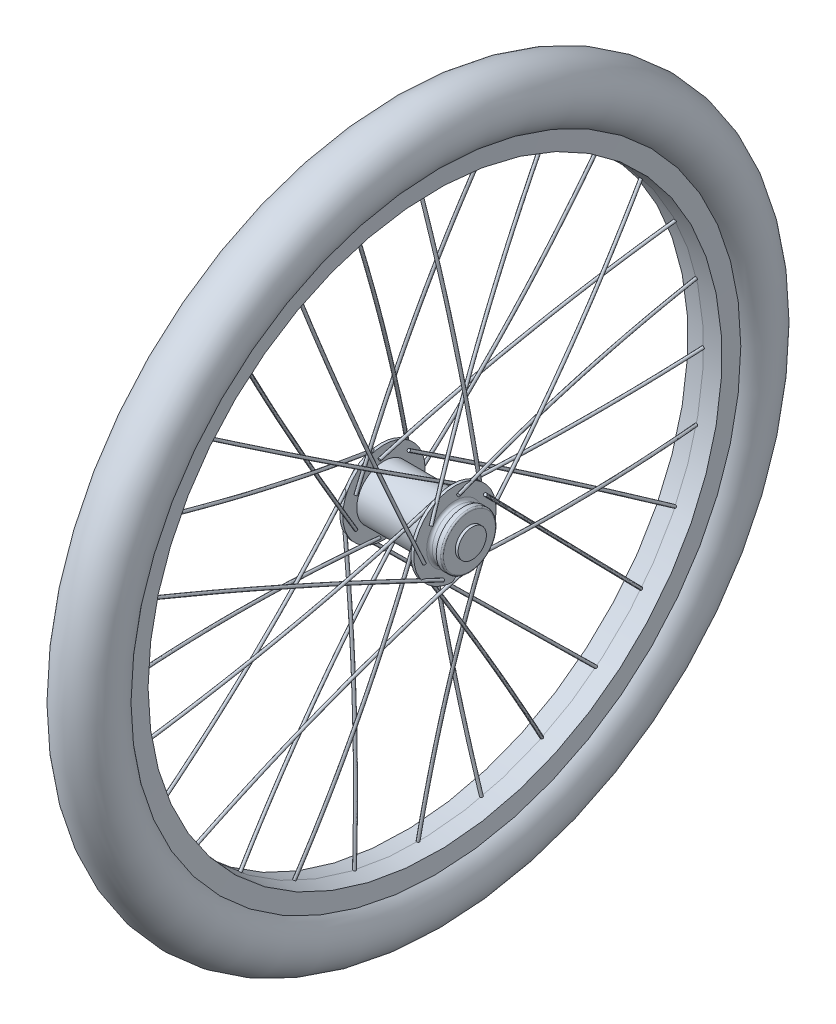
from build123d import *

# Parameters (mm, degrees)
SWEEP1_PROFILE_R      = 1
SWEEP2_PROFILE_R      = 1
BODY_MOVE_COPY1_ANGLE = 12.857142857
CIRPATTERN2_COUNT     = 7
SKETCH38_R            = 18
BOSS_EXTRUDE1_DEPTH   = 6.1
FILLET1_R             = 2
SKETCH39_R            = 19.35
BOSS_EXTRUDE2_DEPTH   = 4.1
FILLET2_R             = 1
SKETCH40_R            = 10
BOSS_EXTRUDE3_DEPTH   = 2


with BuildPart() as part:
    # Sketch1 → Revolve1 (revolve)
    with BuildSketch(Plane.XY):
        with BuildLine():
            Line((12, 202.6), (12.5, 215.46))
            ThreePointArc((12.5, 215.46), (0, 253.334537031), (-12.5, 215.46))
            Line((-12.5, 215.46), (-12, 202.6))
            Line((-12, 202.6), (0, 201.6))
            Line((0, 201.6), (12, 202.6))
        make_face()
    revolve(axis=Axis((0, 0, 0), (1, 0, 0)))


with BuildPart() as body_2:
    # Sketch4 → Revolve2 (revolve)
    with BuildSketch(Plane.XY):
        Polygon((26.125, 0), (26.125, 29.075), (24.075, 29.075), (24.075, 19.14), (0, 19.14), (0, 0), align=None)
    revolve(axis=Axis((0, 0, 0), (1, 0, 0)))

    # Mirror2: body 2 across plane


with BuildPart() as body_2_1:
    add(body_2.part)
    add(body_2.part.mirror(Plane(origin=(0, 0, 0), x_dir=(0, 0, 1), z_dir=(1, 0, 0))))

    # Sketch38 → Boss-Extrude1 (add)
    with BuildSketch(Plane(origin=(26.125, 0, 0), x_dir=(0, 0, -1), z_dir=(1, 0, 0))):
        Circle(SKETCH38_R)
    extrude(amount=BOSS_EXTRUDE1_DEPTH)

    # Fillet1
    fillet1_edges = [body_2_1.edges().sort_by_distance(p)[0] for p in [
        (26.125, 0, 18),
    ]]
    fillet(fillet1_edges, radius=FILLET1_R)

    # Sketch39 → Boss-Extrude2 (add)
    with BuildSketch(Plane(origin=(32.225, 0, 0), x_dir=(0, 0, -1), z_dir=(1, 0, 0))):
        Circle(SKETCH39_R)
    extrude(amount=BOSS_EXTRUDE2_DEPTH)

    # Fillet2
    fillet2_edges = [body_2_1.edges().sort_by_distance(p)[0] for p in [
        (36.325, 0, 19.35),
    ]]
    fillet(fillet2_edges, radius=FILLET2_R)

    # Sketch40 → Boss-Extrude3 (add)
    with BuildSketch(Plane(origin=(36.325, 0, 0), x_dir=(0, 0, -1), z_dir=(1, 0, 0))):
        Circle(SKETCH40_R)
    extrude(amount=BOSS_EXTRUDE3_DEPTH)


with BuildPart() as body_3:
    # Sweep1: sweep along a curve in space
    with BuildLine() as sweep1_path:
        add(Edge.make_bspline(
            [(21.775, 5.451762882, -23.885733848), (18.130892143, 104.226820854, -11.857510805), (0, 201.6, 0)],
            knots=[0, 0, 0, 1, 1, 1], degree=2))
    # Sweep1 profile (on start of the path) → Sweep1 (sweep)
    with BuildSketch(Plane(origin=(21.775, 5.451762882, -23.885733848), x_dir=(0, -0.12088092385501184, 0.9926670147879192), z_dir=(-0.03659792616302885, 0.9920019988619001, 0.12079994227879551))):
        Circle(SWEEP1_PROFILE_R)
    sweep(path=sweep1_path.line)


with BuildPart() as body_4:
    # Sweep2: sweep along a curve in space
    with BuildLine() as sweep2_path:
        add(Edge.make_bspline(
            [(28.425, 15.275500146, 19.15487132), (7.096832985, 97.519487238, -33.558178335), (0, 181.635323769, -87.470961806)],
            knots=[0, 0, 0, 1, 1, 1], degree=2))
    # Sweep2 profile (on start of the path) → Sweep2 (sweep)
    with BuildSketch(Plane(origin=(28.425, 15.275500146, 19.15487132), x_dir=(0, 0.5396120251914962, 0.8419138092873476), z_dir=(-0.2133069514539331, 0.8225373586849968, -0.5271929798744844))):
        Circle(SWEEP2_PROFILE_R)
    sweep(path=sweep2_path.line)


with BuildPart() as body_5:
    # Mirror3: mirrored copy
    add(body_3.part.mirror(Plane(origin=(0, 0, 0), x_dir=(0, 0, 1), z_dir=(1, 0, 0))))


with BuildPart() as body_6:
    # Mirror3 2: mirrored copy
    add(body_4.part.mirror(Plane(origin=(0, 0, 0), x_dir=(0, 0, 1), z_dir=(1, 0, 0))))


with BuildPart() as body_5_1:
    # Body-Move_Copy1: moved
    add(body_5.part.rotate(Axis((0, 0, 0), (1, 0, 0)), BODY_MOVE_COPY1_ANGLE))


with BuildPart() as body_6_1:
    # Body-Move_Copy1: moved
    add(body_6.part.rotate(Axis((0, 0, 0), (1, 0, 0)), BODY_MOVE_COPY1_ANGLE))


with BuildPart() as body_7:
    # Mirror4: mirrored copy
    add(body_6_1.part.mirror(Plane.XY))


with BuildPart() as body_8:
    # Mirror4 2: mirrored copy
    add(body_5_1.part.mirror(Plane.XY))


with BuildPart() as cirpattern2_1:
    # CirPattern2: pattern copy
    add(body_4.part.rotate(Axis((-80.9, 0, 0), (1, 0, 0)), 1 * 360 / CIRPATTERN2_COUNT))


with BuildPart() as cirpattern2_2:
    # CirPattern2: pattern copy
    add(body_4.part.rotate(Axis((-80.9, 0, 0), (1, 0, 0)), 2 * 360 / CIRPATTERN2_COUNT))


with BuildPart() as cirpattern2_3:
    # CirPattern2: pattern copy
    add(body_4.part.rotate(Axis((-80.9, 0, 0), (1, 0, 0)), 3 * 360 / CIRPATTERN2_COUNT))


with BuildPart() as cirpattern2_4:
    # CirPattern2: pattern copy
    add(body_4.part.rotate(Axis((-80.9, 0, 0), (1, 0, 0)), 4 * 360 / CIRPATTERN2_COUNT))


with BuildPart() as cirpattern2_5:
    # CirPattern2: pattern copy
    add(body_4.part.rotate(Axis((-80.9, 0, 0), (1, 0, 0)), 5 * 360 / CIRPATTERN2_COUNT))


with BuildPart() as cirpattern2_6:
    # CirPattern2: pattern copy
    add(body_4.part.rotate(Axis((-80.9, 0, 0), (1, 0, 0)), 6 * 360 / CIRPATTERN2_COUNT))


with BuildPart() as cirpattern2_7:
    # CirPattern2: pattern copy
    add(body_3.part.rotate(Axis((-80.9, 0, 0), (1, 0, 0)), 1 * 360 / CIRPATTERN2_COUNT))


with BuildPart() as cirpattern2_8:
    # CirPattern2: pattern copy
    add(body_3.part.rotate(Axis((-80.9, 0, 0), (1, 0, 0)), 2 * 360 / CIRPATTERN2_COUNT))


with BuildPart() as cirpattern2_9:
    # CirPattern2: pattern copy
    add(body_3.part.rotate(Axis((-80.9, 0, 0), (1, 0, 0)), 3 * 360 / CIRPATTERN2_COUNT))


with BuildPart() as cirpattern2_10:
    # CirPattern2: pattern copy
    add(body_3.part.rotate(Axis((-80.9, 0, 0), (1, 0, 0)), 4 * 360 / CIRPATTERN2_COUNT))


with BuildPart() as cirpattern2_11:
    # CirPattern2: pattern copy
    add(body_3.part.rotate(Axis((-80.9, 0, 0), (1, 0, 0)), 5 * 360 / CIRPATTERN2_COUNT))


with BuildPart() as cirpattern2_12:
    # CirPattern2: pattern copy
    add(body_3.part.rotate(Axis((-80.9, 0, 0), (1, 0, 0)), 6 * 360 / CIRPATTERN2_COUNT))


with BuildPart() as cirpattern2_13:
    # CirPattern2: pattern copy
    add(body_7.part.rotate(Axis((-80.9, 0, 0), (1, 0, 0)), 1 * 360 / CIRPATTERN2_COUNT))


with BuildPart() as cirpattern2_14:
    # CirPattern2: pattern copy
    add(body_7.part.rotate(Axis((-80.9, 0, 0), (1, 0, 0)), 2 * 360 / CIRPATTERN2_COUNT))


with BuildPart() as cirpattern2_15:
    # CirPattern2: pattern copy
    add(body_7.part.rotate(Axis((-80.9, 0, 0), (1, 0, 0)), 3 * 360 / CIRPATTERN2_COUNT))


with BuildPart() as cirpattern2_16:
    # CirPattern2: pattern copy
    add(body_7.part.rotate(Axis((-80.9, 0, 0), (1, 0, 0)), 4 * 360 / CIRPATTERN2_COUNT))


with BuildPart() as cirpattern2_17:
    # CirPattern2: pattern copy
    add(body_7.part.rotate(Axis((-80.9, 0, 0), (1, 0, 0)), 5 * 360 / CIRPATTERN2_COUNT))


with BuildPart() as cirpattern2_18:
    # CirPattern2: pattern copy
    add(body_7.part.rotate(Axis((-80.9, 0, 0), (1, 0, 0)), 6 * 360 / CIRPATTERN2_COUNT))


with BuildPart() as cirpattern2_19:
    # CirPattern2: pattern copy
    add(body_8.part.rotate(Axis((-80.9, 0, 0), (1, 0, 0)), 1 * 360 / CIRPATTERN2_COUNT))


with BuildPart() as cirpattern2_20:
    # CirPattern2: pattern copy
    add(body_8.part.rotate(Axis((-80.9, 0, 0), (1, 0, 0)), 2 * 360 / CIRPATTERN2_COUNT))


with BuildPart() as cirpattern2_21:
    # CirPattern2: pattern copy
    add(body_8.part.rotate(Axis((-80.9, 0, 0), (1, 0, 0)), 3 * 360 / CIRPATTERN2_COUNT))


with BuildPart() as cirpattern2_22:
    # CirPattern2: pattern copy
    add(body_8.part.rotate(Axis((-80.9, 0, 0), (1, 0, 0)), 4 * 360 / CIRPATTERN2_COUNT))


with BuildPart() as cirpattern2_23:
    # CirPattern2: pattern copy
    add(body_8.part.rotate(Axis((-80.9, 0, 0), (1, 0, 0)), 5 * 360 / CIRPATTERN2_COUNT))


with BuildPart() as cirpattern2_24:
    # CirPattern2: pattern copy
    add(body_8.part.rotate(Axis((-80.9, 0, 0), (1, 0, 0)), 6 * 360 / CIRPATTERN2_COUNT))


solid = Compound([part.part, body_2_1.part, body_3.part, body_4.part, body_7.part, body_8.part, cirpattern2_1.part, cirpattern2_2.part, cirpattern2_3.part, cirpattern2_4.part, cirpattern2_5.part, cirpattern2_6.part, cirpattern2_7.part, cirpattern2_8.part, cirpattern2_9.part, cirpattern2_10.part, cirpattern2_11.part, cirpattern2_12.part, cirpattern2_13.part, cirpattern2_14.part, cirpattern2_15.part, cirpattern2_16.part, cirpattern2_17.part, cirpattern2_18.part, cirpattern2_19.part, cirpattern2_20.part, cirpattern2_21.part, cirpattern2_22.part, cirpattern2_23.part, cirpattern2_24.part])
